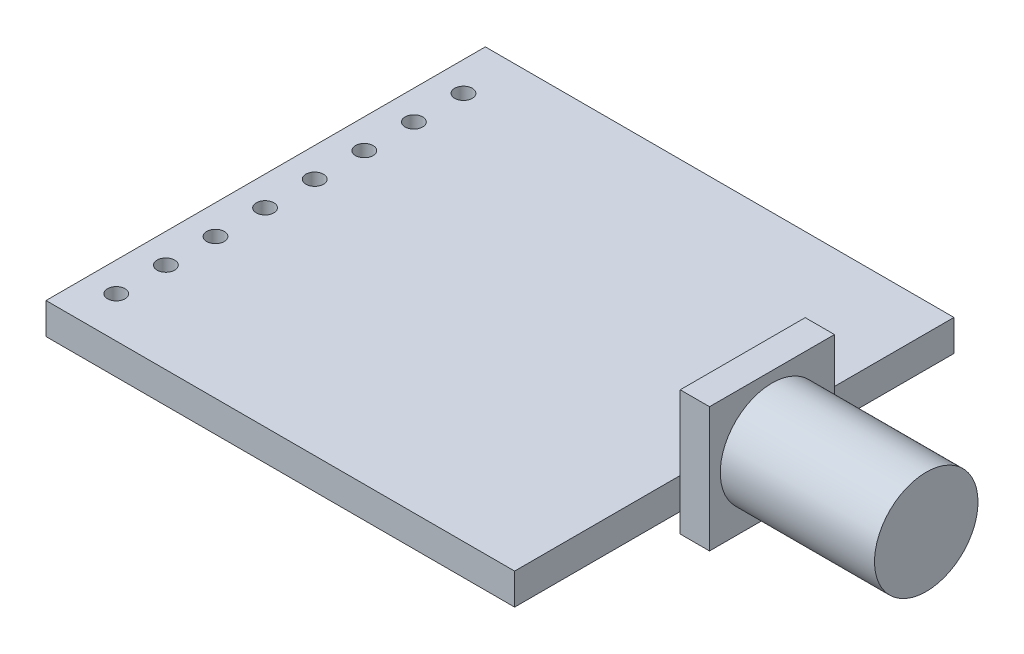
from build123d import *

# Parameters (mm, degrees)
SKETCH1_W           = 24
SKETCH1_H           = 22.5
BOSS_EXTRUDE1_DEPTH = 1.6
SKETCH2_W           = 6.4
SKETCH2_H           = 6.4
BOSS_EXTRUDE2_DEPTH = 1.5
SKETCH3_R           = 2.65
BOSS_EXTRUDE3_DEPTH = 7.9
SKETCH4_R           = 0.45
CUT_EXTRUDE1_DEPTH  = 3.6
LPATTERN1_COUNT     = 8
LPATTERN1_PITCH     = 2.54


with BuildPart() as part:
    # Sketch1 → Boss-Extrude1 (new body)
    with BuildSketch(Plane(origin=(0, 0, 0), x_dir=(1, 0, 0), z_dir=(0, 1, 0))):
        Rectangle(SKETCH1_W, SKETCH1_H)
    extrude(amount=BOSS_EXTRUDE1_DEPTH)

    # Sketch2 → Boss-Extrude2 (add)
    with BuildSketch(Plane(origin=(12, 0, 0), x_dir=(0, 0, -1), z_dir=(1, 0, 0))):
        with Locations((0.431041527, 2.2)):
            Rectangle(SKETCH2_W, SKETCH2_H)
    extrude(amount=BOSS_EXTRUDE2_DEPTH)

    # Sketch3 → Boss-Extrude3 (add)
    with BuildSketch(Plane(origin=(13.5, 0, 0), x_dir=(0, 0, -1), z_dir=(1, 0, 0))):
        with Locations((0.431041527, 2.2)):
            Circle(SKETCH3_R)
    extrude(amount=BOSS_EXTRUDE3_DEPTH)

    # Sketch4 → Cut-Extrude1 (cut, through all)
    with BuildSketch(Plane(origin=(0, 1.6, 0), x_dir=(1, 0, 0), z_dir=(0, 1, 0))):
        with Locations((-10.5, -9.15)):
            Circle(SKETCH4_R)
    cut_extrude1 = extrude(amount=-CUT_EXTRUDE1_DEPTH, mode=Mode.SUBTRACT)

    # LPattern1: Cut-Extrude1 ×8
    with Locations(*[(0, 0, -i * LPATTERN1_PITCH) for i in range(1, LPATTERN1_COUNT)]):
        add(cut_extrude1, mode=Mode.SUBTRACT)


solid = part.part
